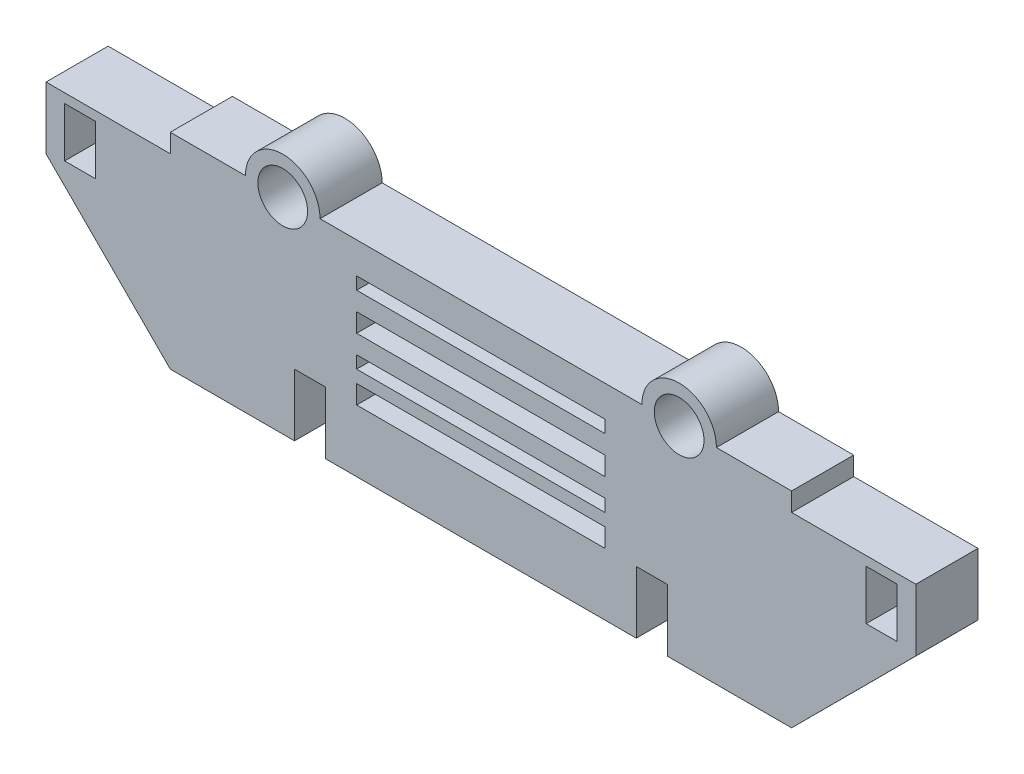
from build123d import *

# Parameters (mm, degrees)
CROQUIS1_W              = 40
CROQUIS1_H              = 3
CROQUIS1_H_2            = 2
CROQUIS1_W_2            = 5
CROQUIS1_H_3            = 8
CROQUIS1_R              = 4
SALIENTE_EXTRUIR1_DEPTH = 10


with BuildPart() as part:
    # Croquis1 → Saliente-Extruir1 (new body)
    with BuildSketch(Plane.XY):
        with BuildLine():
            Line((-25, 10), (-25, 0))
            Line((-25, 0), (25, 0))
            Line((25, 0), (25, 10))
            Line((25, 10), (30, 10))
            Line((30, 10), (30, 0))
            Line((30, 0), (50, 0))
            Line((50, 0), (70, 20.022237637))
            Line((70, 20.022237637), (70, 30.022237637))
            Line((70, 30.022237637), (50, 30.022237637))
            Line((50, 30.022237637), (50, 33.022237637))
            Line((50, 33.022237637), (37.9, 33.022237637))
            ThreePointArc((37.9, 33.022237637), (31.9, 39.022237637), (25.9, 33.022237637))
            Line((25.9, 33.022237637), (-25.9, 33.022237637))
            ThreePointArc((-25.9, 33.022237637), (-31.9, 39.022237637), (-37.9, 33.022237637))
            Line((-37.9, 33.022237637), (-50, 33.022237637))
            Line((-50, 33.022237637), (-50, 30.022237637))
            Line((-50, 30.022237637), (-70, 30.022237637))
            Line((-70, 30.022237637), (-70, 20.022237637))
            Line((-70, 20.022237637), (-50, 0))
            Line((-50, 0), (-30, 0))
            Line((-30, 0), (-30, 10))
            Line((-30, 10), (-25, 10))
        make_face()
        with Locations((0, 11.5)):
            Rectangle(CROQUIS1_W, CROQUIS1_H, mode=Mode.SUBTRACT)
        with Locations((0, 16)):
            Rectangle(CROQUIS1_W, CROQUIS1_H_2, mode=Mode.SUBTRACT)
        with Locations((-64.5, 24.522237637)):
            Rectangle(CROQUIS1_W_2, CROQUIS1_H_3, mode=Mode.SUBTRACT)
        with BuildLine():
            ThreePointArc((-27.9, 33.022237637), (-31.9, 29.022237637), (-35.9, 33.022237637))
            ThreePointArc((-35.9, 33.022237637), (-31.9, 37.022237637), (-27.9, 33.022237637))
        make_face(mode=Mode.SUBTRACT)
        with Locations((0, 21.5)):
            Rectangle(CROQUIS1_W, CROQUIS1_H, mode=Mode.SUBTRACT)
        with Locations((0, 27)):
            Rectangle(CROQUIS1_W, CROQUIS1_H_2, mode=Mode.SUBTRACT)
        with Locations((64.5, 24.522237637)):
            Rectangle(CROQUIS1_W_2, CROQUIS1_H_3, mode=Mode.SUBTRACT)
        with Locations((31.9, 33.022237637)):
            Circle(CROQUIS1_R, mode=Mode.SUBTRACT)
    extrude(amount=SALIENTE_EXTRUIR1_DEPTH)


solid = part.part
